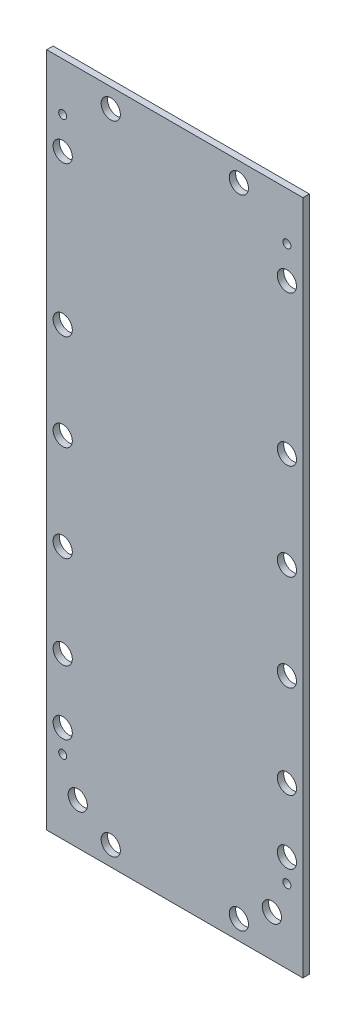
from build123d import *

# Parameters (mm, degrees)
SKETCH2_W                 = 80
SKETCH2_H                 = 211
BOSS_EXTRUDE1_DEPTH       = 2
M3X0_5_TAPPED_HOLE1_D     = 2.5
M3X0_5_TAPPED_HOLE1_DEPTH = 10
M3X0_5_TAPPED_HOLE1_TIP   = 0.751075774
SKETCH7_R                 = 3
CUT_EXTRUDE1_DEPTH        = 2


with BuildPart() as part:
    # Sketch2 → Boss-Extrude1 (new body)
    with BuildSketch(Plane.XY):
        with Locations((40, 105.5)):
            Rectangle(SKETCH2_W, SKETCH2_H)
    extrude(amount=BOSS_EXTRUDE1_DEPTH)

    # M3x0.5 Tapped Hole1
    with Locations(Plane(origin=(0, 0, 0), x_dir=(-1, 0, 0), z_dir=(0, 0, -1))):
        with Locations((-75, 196), (-5, 196), (-75, 23), (-5, 23)):
            Hole(M3X0_5_TAPPED_HOLE1_D / 2, depth=M3X0_5_TAPPED_HOLE1_DEPTH)
            with Locations((0, 0, -(M3X0_5_TAPPED_HOLE1_DEPTH + M3X0_5_TAPPED_HOLE1_TIP / 2))):  # 118° drill point
                Cone(0, M3X0_5_TAPPED_HOLE1_D / 2, M3X0_5_TAPPED_HOLE1_TIP, mode=Mode.SUBTRACT)

    # Sketch7 → Cut-Extrude1 (cut)
    with BuildSketch(Plane(origin=(0, 0, 0), x_dir=(-1, 0, 0), z_dir=(0, 0, -1))):
        with Locations((-75, 186)):
            Circle(SKETCH7_R)
        with Locations((-75, 139.2)):
            Circle(SKETCH7_R)
        with Locations((-75, 109.2)):
            Circle(SKETCH7_R)
        with Locations((-75, 79.2)):
            Circle(SKETCH7_R)
        with Locations((-75, 50.2)):
            Circle(SKETCH7_R)
        with Locations((-75, 30.2)):
            Circle(SKETCH7_R)
        with Locations((-5, 186)):
            Circle(SKETCH7_R)
        with Locations((-5, 139.2)):
            Circle(SKETCH7_R)
        with Locations((-5, 109.2)):
            Circle(SKETCH7_R)
        with Locations((-5, 79.2)):
            Circle(SKETCH7_R)
        with Locations((-5, 50.2)):
            Circle(SKETCH7_R)
        with Locations((-5, 30.2)):
            Circle(SKETCH7_R)
        with Locations((-70.3, 13)):
            Circle(SKETCH7_R)
        with Locations((-60, 205)):
            Circle(SKETCH7_R)
        with Locations((-20, 205)):
            Circle(SKETCH7_R)
        with Locations((-60, 6)):
            Circle(SKETCH7_R)
        with Locations((-20, 6)):
            Circle(SKETCH7_R)
        with Locations((-9.7, 13)):
            Circle(SKETCH7_R)
    extrude(amount=-CUT_EXTRUDE1_DEPTH, mode=Mode.SUBTRACT)


solid = part.part
